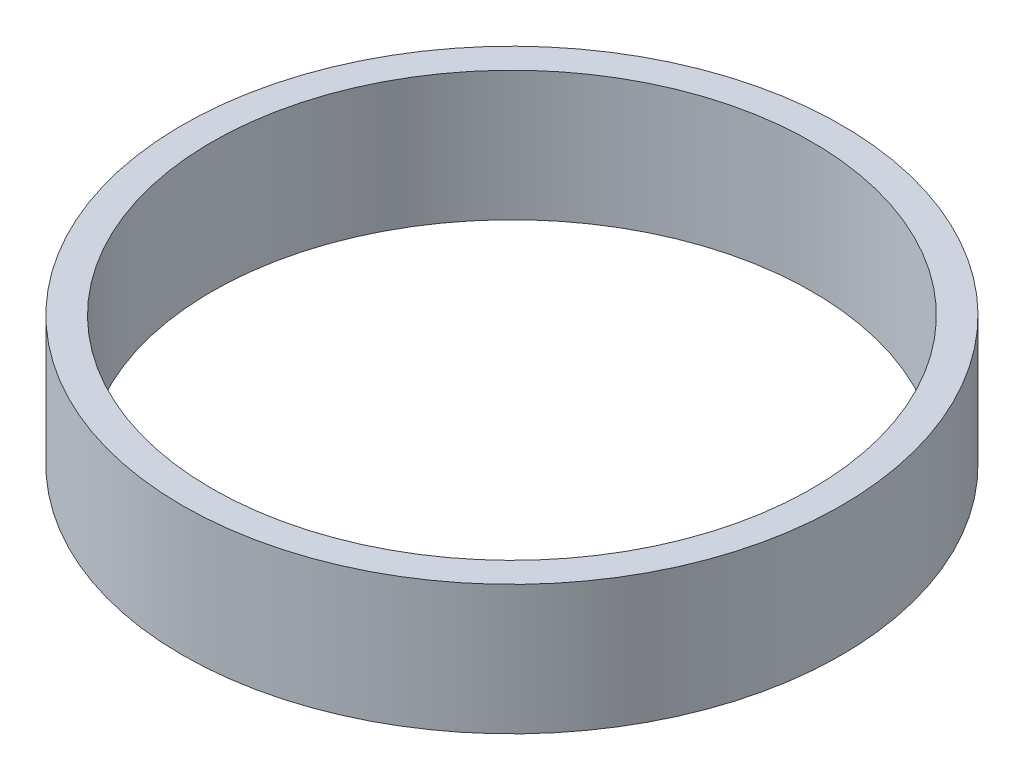
from build123d import *

# Parameters (mm, degrees)
SKETCH_1_R      = 28
SKETCH_1_R_2    = 25.5
EXTRUDE_1_DEPTH = 11


with BuildPart() as part:
    # 草图1 → 凸台-拉伸1 (new body)
    with BuildSketch(Plane(origin=(0, 0, 0), x_dir=(1, 0, 0), z_dir=(0, 1, 0))):
        with Locations(Location((0, 0, 0), (0, 0, 270))):  # turned: the seam where the file's is
            Circle(SKETCH_1_R)
        with Locations(Location((0, 0, 0), (0, 0, 270))):  # turned: the seam where the file's is
            Circle(SKETCH_1_R_2, mode=Mode.SUBTRACT)
    extrude(amount=EXTRUDE_1_DEPTH)


solid = part.part
